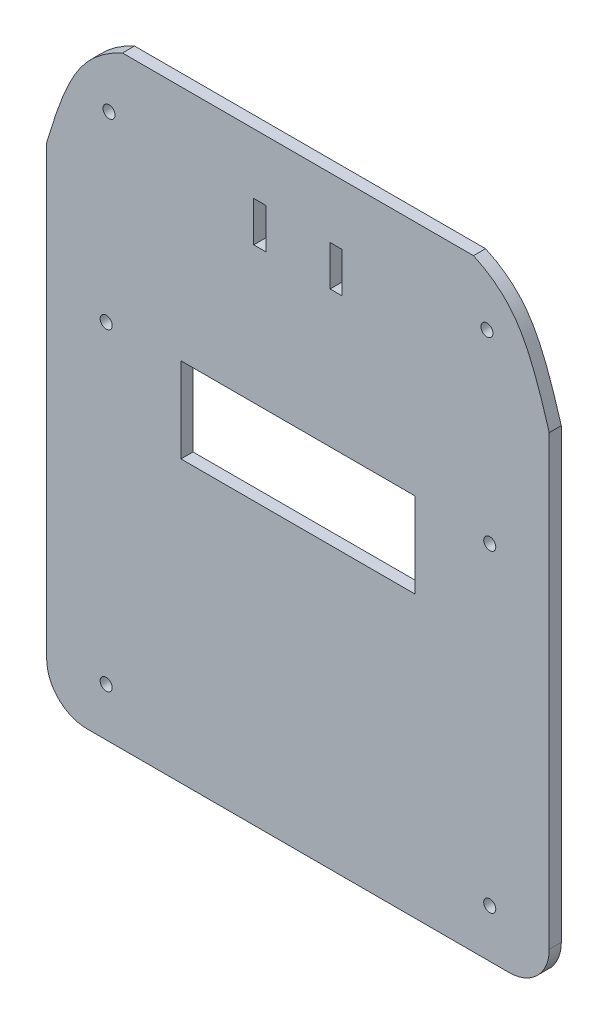
from build123d import *

# Parameters (mm, degrees)
SKETCH1_W           = 125
SKETCH1_H           = 150
BOSS_EXTRUDE1_DEPTH = 3
SKETCH6_R           = 1.5
CUT_EXTRUDE5_DEPTH  = 4
CUT_EXTRUDE6_DEPTH  = 4
SKETCH8_R           = 1.5
CUT_EXTRUDE7_DEPTH  = 4.0000001
FILLET1_R           = 10
SKETCH10_W          = 58.197172172
SKETCH10_H          = 21.139257973
CUT_EXTRUDE8_DEPTH  = 4.0000001
SKETCH11_W          = 3
SKETCH11_H          = 10
CUT_EXTRUDE9_DEPTH  = 4.0000001


with BuildPart() as part:
    # Sketch1 → Boss-Extrude1 (new body)
    with BuildSketch(Plane.XY):
        with Locations((62.5, 75)):
            Rectangle(SKETCH1_W, SKETCH1_H)
    extrude(amount=BOSS_EXTRUDE1_DEPTH)

    # Sketch6 → Cut-Extrude5 (cut, through all)
    with BuildSketch(Plane(origin=(0, 0, 0), x_dir=(-1, 0, 0), z_dir=(0, 0, -1))):
        with Locations((-15.5, 135.678181118)):
            Circle(SKETCH6_R)
        with Locations((-109.5, 135.678181118)):
            Circle(SKETCH6_R)
    extrude(amount=-CUT_EXTRUDE5_DEPTH, mode=Mode.SUBTRACT)

    # Sketch7 → Cut-Extrude6 (cut, through all)
    with BuildSketch(Plane.XY.offset(3)):
        with BuildLine():
            Line((18.83856041, 150), (0, 150))
            Line((0, 150), (0, 121.303805561))
            add(Edge.make_bspline(
                [(0, 121.303805561), (5.130729703, 138.554109372), (8.057120528, 143.174726465), (13.293819899, 147.487302418), (18.83856041, 150)],
                knots=[0, 0, 0, 0, 0, 1, 1, 1, 1, 1], degree=4))
        make_face()
        with BuildLine():
            Line((125, 150), (125, 121.303805561))
            add(Edge.make_bspline(
                [(125, 121.303805561), (119.869270297, 138.554109372), (116.942879472, 143.174726465), (111.706180101, 147.487302418), (106.16143959, 150)],
                knots=[0, 0, 0, 0, 0, 1, 1, 1, 1, 1], degree=4))
            Line((106.16143959, 150), (125, 150))
        make_face()
    extrude(amount=-CUT_EXTRUDE6_DEPTH, mode=Mode.SUBTRACT)

    # Sketch8 → Cut-Extrude7 (cut, through all)
    with BuildSketch(Plane.XY.offset(3)):
        with Locations((14.8, 12)):
            Circle(SKETCH8_R)
        with Locations((110.2, 12)):
            Circle(SKETCH8_R)
        with Locations((14.8, 90)):
            Circle(SKETCH8_R)
        with Locations((110.2, 90)):
            Circle(SKETCH8_R)
    extrude(amount=-CUT_EXTRUDE7_DEPTH, mode=Mode.SUBTRACT)

    # Fillet1
    fillet1_edges = [part.edges().sort_by_distance(p)[0] for p in [
        (125, 0, 1.5),
        (0, 0, 1.5),
    ]]
    fillet(fillet1_edges, radius=FILLET1_R)

    # Sketch10 → Cut-Extrude8 (cut, through all)
    with BuildSketch(Plane.XY.offset(3)):
        with Locations((62.5, 80.404070369)):
            Rectangle(SKETCH10_W, SKETCH10_H)
    extrude(amount=-CUT_EXTRUDE8_DEPTH, mode=Mode.SUBTRACT)

    # Sketch11 → Cut-Extrude9 (cut, through all)
    with BuildSketch(Plane.XY.offset(3)):
        with Locations((72, 130)):
            Rectangle(SKETCH11_W, SKETCH11_H)
        with Locations((53, 130)):
            Rectangle(SKETCH11_W, SKETCH11_H)
    extrude(amount=-CUT_EXTRUDE9_DEPTH, mode=Mode.SUBTRACT)


solid = part.part
